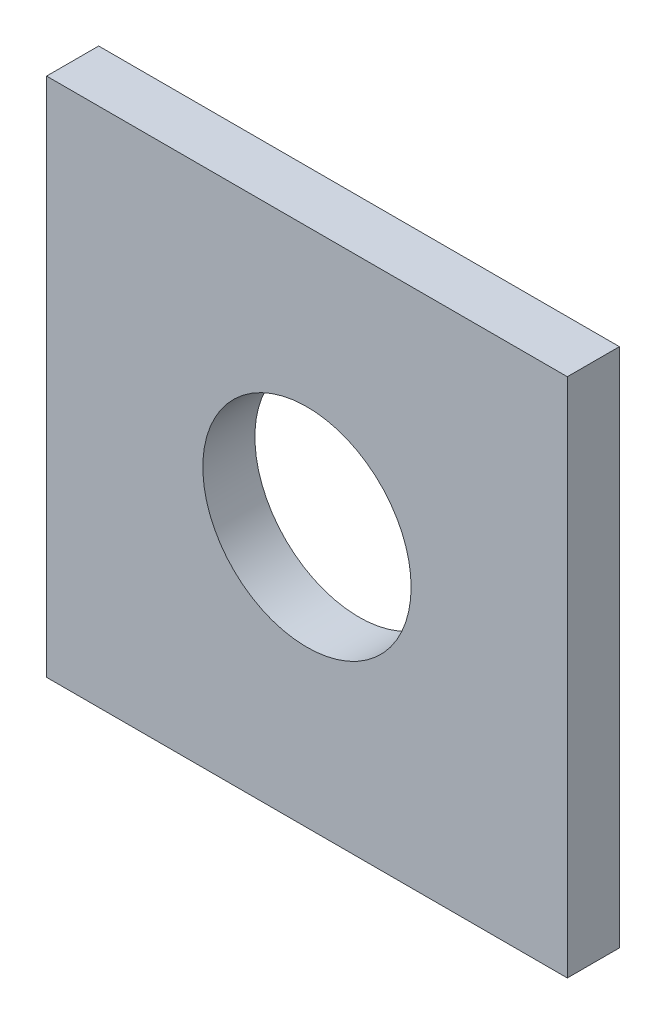
from build123d import *

# Parameters (mm, degrees)
ESBO_O1_W                = 10
ESBO_O1_H                = 10
ESBO_O1_R                = 2
RESSALTO_EXTRUS_O1_DEPTH = 1


with BuildPart() as part:
    # Esboço1 → Ressalto-extrusão1 (new body)
    with BuildSketch(Plane.XY):
        with Locations((5, 5)):
            Rectangle(ESBO_O1_W, ESBO_O1_H)
        with Locations((5, 5)):
            Circle(ESBO_O1_R, mode=Mode.SUBTRACT)
    extrude(amount=RESSALTO_EXTRUS_O1_DEPTH)


solid = part.part
